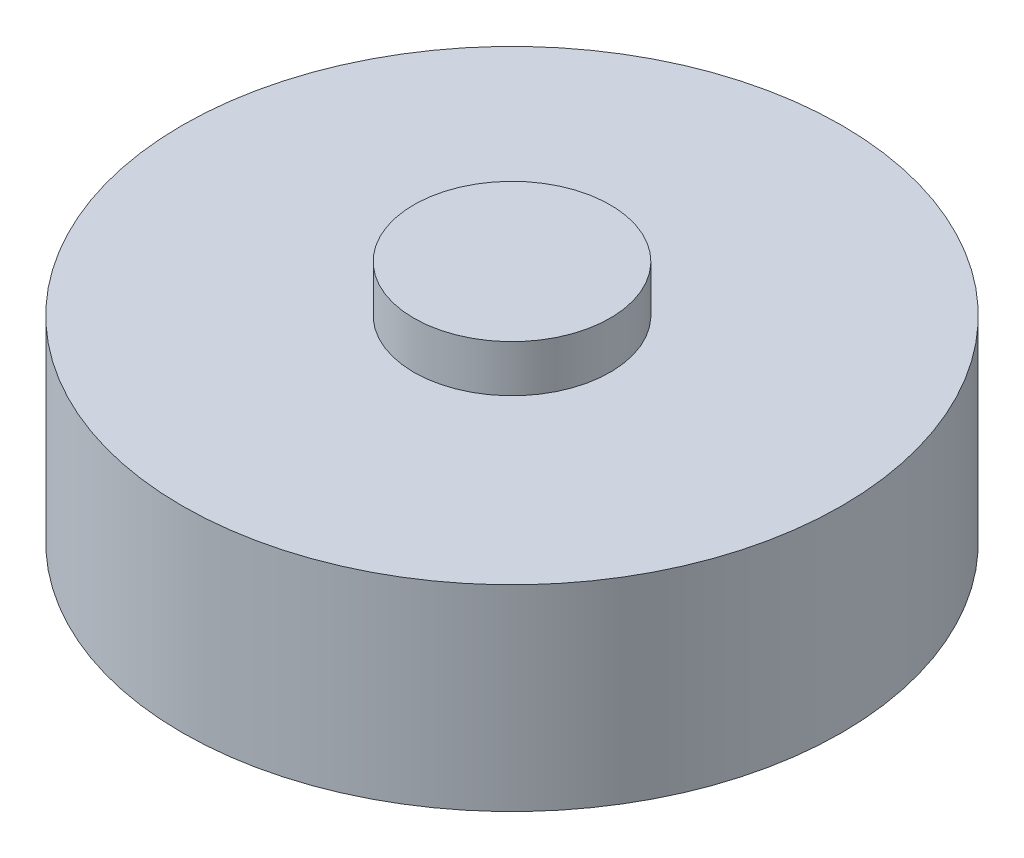
from build123d import *

# Parameters (mm, degrees)
SKETCH1_R           = 29.845
BOSS_EXTRUDE1_DEPTH = 17.78
SKETCH2_R           = 8.89
BOSS_EXTRUDE2_DEPTH = 4.2418
SKETCH3_R           = 7.493
BOSS_EXTRUDE3_DEPTH = 4.064
SKETCH4_R           = 8.255
BOSS_EXTRUDE4_DEPTH = 0.762
SKETCH6_R           = 0.95
CUT_EXTRUDE1_DEPTH  = 25.4


with BuildPart() as part:
    # Sketch1 → Boss-Extrude1 (new body)
    with BuildSketch(Plane(origin=(0, 0, 0), x_dir=(1, 0, 0), z_dir=(0, 1, 0))):
        Circle(SKETCH1_R)
    extrude(amount=BOSS_EXTRUDE1_DEPTH)

    # Sketch2 → Boss-Extrude2 (add)
    with BuildSketch(Plane(origin=(0, 17.78, 0), x_dir=(1, 0, 0), z_dir=(0, 1, 0))):
        Circle(SKETCH2_R)
    extrude(amount=BOSS_EXTRUDE2_DEPTH)

    # Sketch3 → Boss-Extrude3 (add)
    with BuildSketch(Plane(origin=(0, 0, 0), x_dir=(-1, 0, 0), z_dir=(0, -1, 0))):
        Circle(SKETCH3_R)
    extrude(amount=BOSS_EXTRUDE3_DEPTH)

    # Sketch4 → Boss-Extrude4 (add)
    with BuildSketch(Plane.XZ.offset(4.064)):
        Circle(SKETCH4_R)
    extrude(amount=BOSS_EXTRUDE4_DEPTH)

    # Sketch6 → Cut-Extrude1 (cut)
    with BuildSketch(Plane(origin=(0, -4.826, 0), x_dir=(-1, 0, 0), z_dir=(0, -1, 0))):
        with BuildLine():
            Line((-2.33826859, -1.35), (2.33826859, -1.35))
            ThreePointArc((2.33826859, -1.35), (2.7, 0), (2.33826859, 1.35))
            Line((2.33826859, 1.35), (-2.33826859, 1.35))
            ThreePointArc((-2.33826859, 1.35), (-2.7, 0), (-2.33826859, -1.35))
        make_face()
        Circle(SKETCH6_R, mode=Mode.SUBTRACT)
    extrude(amount=-CUT_EXTRUDE1_DEPTH, mode=Mode.SUBTRACT)


solid = part.part
